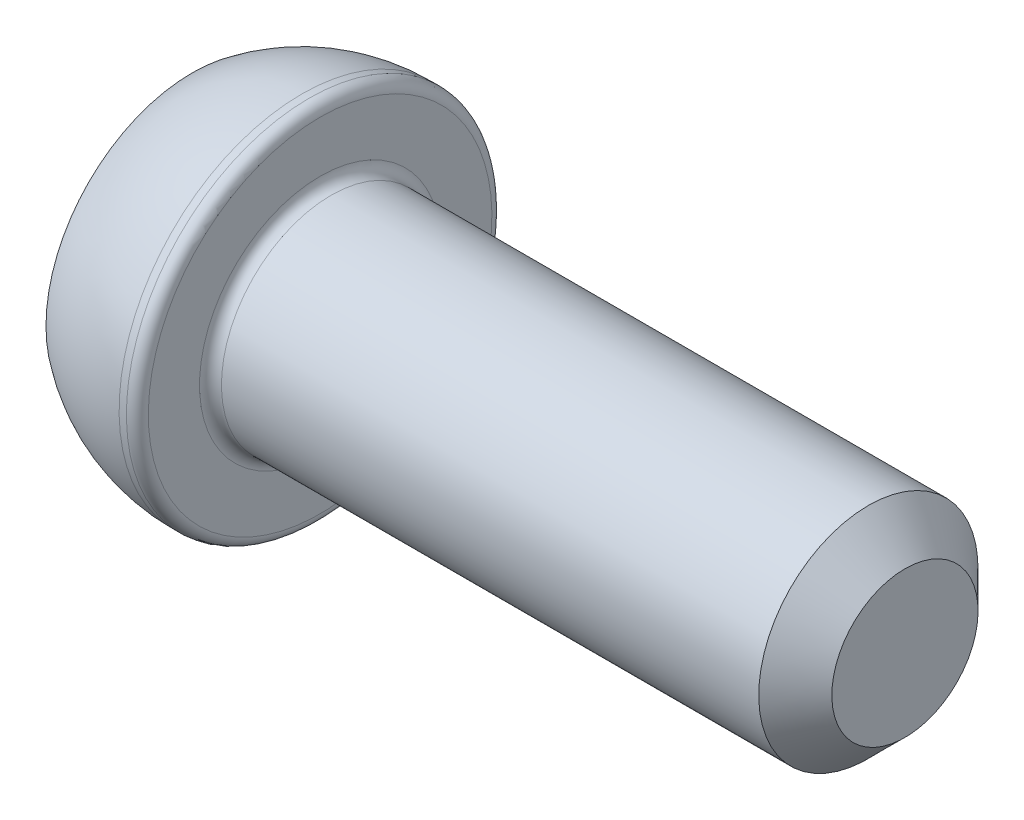
from build123d import *

# Parameters (mm, degrees)
CUT_EXTRUDE_1_DEPTH = 2
FILLET_1_R          = 0.3
CHAMFER_1_SIZE      = 1


with BuildPart() as part:
    # Эскиз1 → Повернуть1 (revolve)
    with BuildSketch(Plane.XY):
        with BuildLine():
            Line((0, 0), (0, 4))
            ThreePointArc((0, 4), (1.41886117, 4.74341649), (3, 5))
            Line((3, 5), (3.5, 5))
            Line((3.5, 5), (3.5, 3))
            Line((3.5, 3), (19.5, 3))
            Line((19.5, 3), (19.5, 0))
            Line((19.5, 0), (0, 0))
        make_face()
    revolve(axis=Axis((19.5, 0, 0), (-1, 0, 0)))

    # Эскиз2 → Вырез-Вытянуть1 (cut)
    with BuildSketch(Plane.ZY):
        Polygon((1.154700538, 2), (-1.154700538, 2), (-2.309401077, 0), (-1.154700538, -2), (1.154700538, -2), (2.309401077, 0), align=None)
    extrude(amount=-CUT_EXTRUDE_1_DEPTH, mode=Mode.SUBTRACT)

    # Скругление1
    fillet_1_edges = [part.edges().sort_by_distance(p)[0] for p in [
        (3.5, -3, 0),
        (3.5, -5, 0),
    ]]
    fillet(fillet_1_edges, radius=FILLET_1_R)

    # Фаска1
    chamfer_1_edges = [part.edges().sort_by_distance(p)[0] for p in [
        (19.5, -3, 0),
    ]]
    chamfer(chamfer_1_edges, length=CHAMFER_1_SIZE)


solid = part.part
